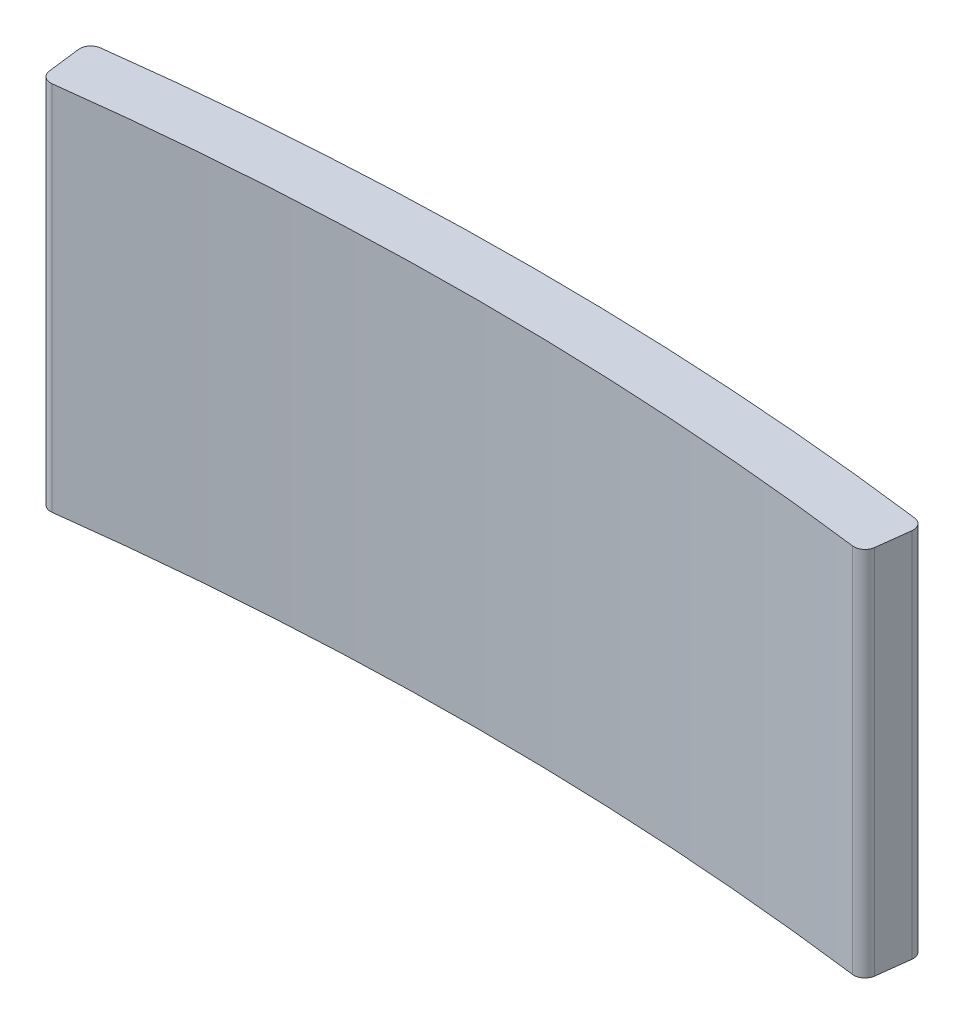
from build123d import *

# Parameters (mm, degrees)
RESSALTO_EXTRUS_O2_DEPTH = 10
FILETE1_R                = 0.3


with BuildPart() as part:
    # Esboço1 → Ressalto-extrusão2 (new body)
    with BuildSketch(Plane(origin=(0, 0, 0), x_dir=(1, 0, 0), z_dir=(0, 1, 0))):
        with BuildLine():
            Line((11.080017789, 84.274748328), (11.262828374, 85.763621058))
            ThreePointArc((11.262828374, 85.763621058), (-0.000523598, 86.499999998), (-11.263866654, 85.763484701))
            Line((-11.263866654, 85.763484701), (-11.081056051, 84.274611816))
            ThreePointArc((-11.081056051, 84.274611816), (-0.000523599, 84.999999998), (11.080017789, 84.274748328))
        make_face()
    extrude(amount=RESSALTO_EXTRUS_O2_DEPTH)

    # Filete1
    filete1_edges = [part.edges().sort_by_distance(p)[0] for p in [
        (-11.081056051, 5, -84.274611816),
        (-11.263866654, 5, -85.763484701),
        (11.262828374, 5, -85.763621058),
        (11.080017789, 5, -84.274748328),
    ]]
    fillet(filete1_edges, radius=FILETE1_R)


solid = part.part
